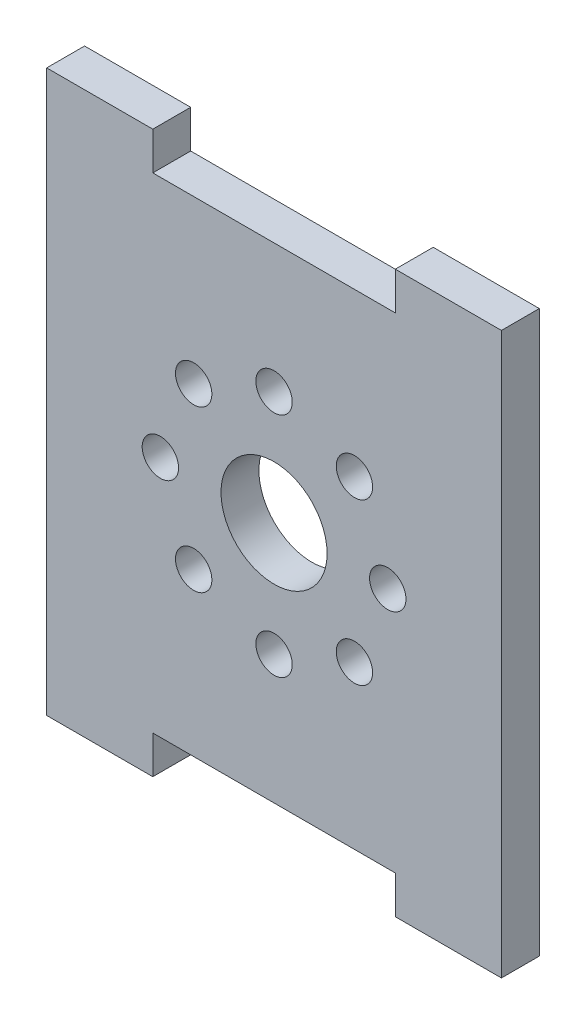
from build123d import *

# Parameters (mm, degrees)
CROQUIS1_R              = 3.5
CROQUIS1_R_2            = 1.2
SALIENTE_EXTRUIR1_DEPTH = 1.25


with BuildPart() as part:
    # Croquis1 → Saliente-Extruir1 (new body, symmetric)
    with BuildSketch(Plane.XY):
        Polygon((-15, 18.5), (-8, 18.5), (-8, 16), (8, 16), (8, 18.5), (15, 18.5), (15, -18.5), (8, -18.5), (8, -16), (-8, -16), (-8, -18.5), (-15, -18.5), align=None)
        Circle(CROQUIS1_R, mode=Mode.SUBTRACT)
        with Locations((0, 7.5)):
            Circle(CROQUIS1_R_2, mode=Mode.SUBTRACT)
        with Locations((5.303300859, 5.303300859)):
            Circle(CROQUIS1_R_2, mode=Mode.SUBTRACT)
        with Locations((7.5, 0)):
            Circle(CROQUIS1_R_2, mode=Mode.SUBTRACT)
        with Locations((5.303300859, -5.303300859)):
            Circle(CROQUIS1_R_2, mode=Mode.SUBTRACT)
        with Locations((0, -7.5)):
            Circle(CROQUIS1_R_2, mode=Mode.SUBTRACT)
        with Locations((-5.303300859, -5.303300859)):
            Circle(CROQUIS1_R_2, mode=Mode.SUBTRACT)
        with Locations((-7.5, 0)):
            Circle(CROQUIS1_R_2, mode=Mode.SUBTRACT)
        with Locations((-5.303300859, 5.303300859)):
            Circle(CROQUIS1_R_2, mode=Mode.SUBTRACT)
    extrude(amount=SALIENTE_EXTRUIR1_DEPTH, both=True)


solid = part.part
